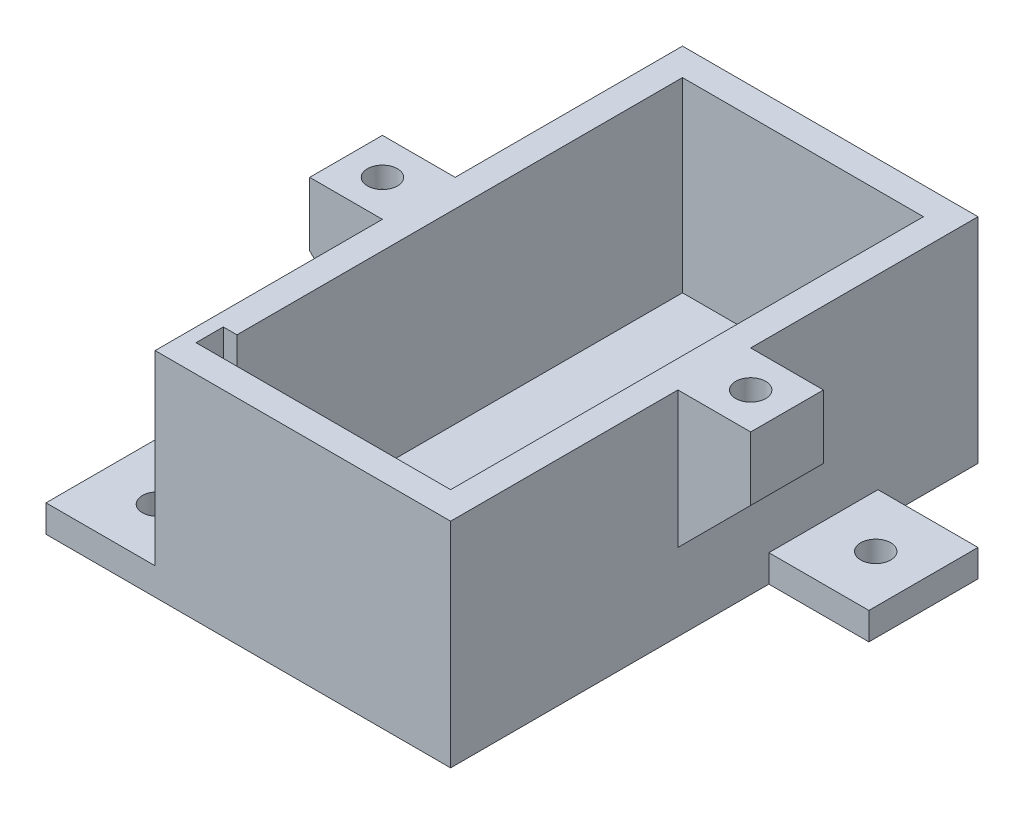
from build123d import *

# Parameters (mm, degrees)
BOSS_EXTRUDE1_DEPTH = 52
SKETCH2_W           = 32.5
SKETCH2_H           = 23.5
BOSS_EXTRUDE2_DEPTH = 3
SKETCH3_W           = 8
SKETCH3_H           = 8
SKETCH3_R           = 1.65
BOSS_EXTRUDE3_DEPTH = 15
CUT_EXTRUDE1_START  = -2.3
CUT_EXTRUDE1_DEPTH  = 2.4
CUT_EXTRUDE2_DEPTH  = 34
SKETCH6_W           = 32.5
SKETCH6_H           = 23.5
BOSS_EXTRUDE5_DEPTH = 3
SKETCH7_W           = 10
SKETCH7_H           = 10
CUT_EXTRUDE3_DEPTH  = 3
SKETCH8_W           = 9.75
SKETCH8_H           = 3
CUT_EXTRUDE4_DEPTH  = 22
SKETCH9_W           = 11
SKETCH9_H           = 12
SKETCH9_R           = 1.65
SKETCH9_W_2         = 12
BOSS_EXTRUDE6_DEPTH = 3


with BuildPart() as part:
    # Sketch1 → Boss-Extrude1 (new body)
    with BuildSketch(Plane.XY):
        Polygon((3, 20.5), (3, 23.5), (0, 23.5), (0, 0), (32.5, 0), (32.5, 23.5), (29.5, 23.5), (29.5, 20.5), (29.5, 3), (3, 3), align=None)
    extrude(amount=BOSS_EXTRUDE1_DEPTH)

    # Sketch2 → Boss-Extrude2 (add)
    with BuildSketch(Plane(origin=(0, 0, 0), x_dir=(-1, 0, 0), z_dir=(0, 0, -1))):
        with Locations((-16.25, 11.75)):
            Rectangle(SKETCH2_W, SKETCH2_H)
    extrude(amount=BOSS_EXTRUDE2_DEPTH)

    # Sketch3 → Boss-Extrude3 (add)
    with BuildSketch(Plane(origin=(0, 23.5, 0), x_dir=(1, 0, 0), z_dir=(0, 1, 0))):
        with Locations((-4, -26)):
            Rectangle(SKETCH3_W, SKETCH3_H)
        with Locations((-4, -26)):
            Circle(SKETCH3_R, mode=Mode.SUBTRACT)
        with Locations((36.5, -26)):
            Rectangle(SKETCH3_W, SKETCH3_H)
        with Locations((36.5, -26)):
            Circle(SKETCH3_R, mode=Mode.SUBTRACT)
    extrude(amount=-BOSS_EXTRUDE3_DEPTH)

    # Sketch4 → Cut-Extrude1 (cut)
    with BuildSketch(Plane(origin=(0, 23.5, 0), x_dir=(1, 0, 0), z_dir=(0, 1, 0)).offset(CUT_EXTRUDE1_START)):
        Polygon((-1.067108801, -27.360691938), (-1.355160616, -24.140387685), (-4.288051814, -22.779695746), (-6.932891199, -24.639308062), (-6.644839384, -27.859612315), (-3.711948186, -29.220304254), align=None)
        Polygon((39.432891199, -27.360691938), (39.144839384, -24.140387685), (36.211948186, -22.779695746), (33.567108801, -24.639308062), (33.855160616, -27.859612315), (36.788051814, -29.220304254), align=None)
    extrude(amount=-CUT_EXTRUDE1_DEPTH, mode=Mode.SUBTRACT)

    # Sketch5 → Cut-Extrude2 (cut, through all)
    with BuildSketch(Plane.XY.offset(30)):
        Polygon((40.5, 8.5), (32.5, 8.5), (40.5, 16.5), align=None)
        Polygon((-8, 8.5), (0, 8.5), (-8, 16.5), align=None)
    extrude(amount=-CUT_EXTRUDE2_DEPTH, mode=Mode.SUBTRACT)

    # Sketch6 → Boss-Extrude5 (add)
    with BuildSketch(Plane.XY.offset(52)):
        with Locations((16.25, 11.75)):
            Rectangle(SKETCH6_W, SKETCH6_H)
    extrude(amount=BOSS_EXTRUDE5_DEPTH)

    # Sketch7 → Cut-Extrude3 (cut)
    with BuildSketch(Plane(origin=(0, 3, 0), x_dir=(1, 0, 0), z_dir=(0, 1, 0))):
        with Locations((8, -47)):
            Rectangle(SKETCH7_W, SKETCH7_H)
    extrude(amount=-CUT_EXTRUDE3_DEPTH, mode=Mode.SUBTRACT)

    # Sketch8 → Cut-Extrude4 (cut)
    with BuildSketch(Plane(origin=(0, 23.5, 0), x_dir=(1, 0, 0), z_dir=(0, 1, 0))):
        with Locations((6.375, -50.5)):
            Rectangle(SKETCH8_W, SKETCH8_H)
    extrude(amount=-CUT_EXTRUDE4_DEPTH, mode=Mode.SUBTRACT)

    # Sketch9 → Boss-Extrude6 (add)
    with BuildSketch(Plane.XZ):
        with Locations((38, 14)):
            Rectangle(SKETCH9_W, SKETCH9_H)
        with Locations((38.25, 14)):
            Circle(SKETCH9_R, mode=Mode.SUBTRACT)
        with Locations((-6, 49)):
            Rectangle(SKETCH9_W_2, SKETCH9_H)
        with Locations((-5.75, 49)):
            Circle(SKETCH9_R, mode=Mode.SUBTRACT)
    extrude(amount=-BOSS_EXTRUDE6_DEPTH)


solid = part.part
